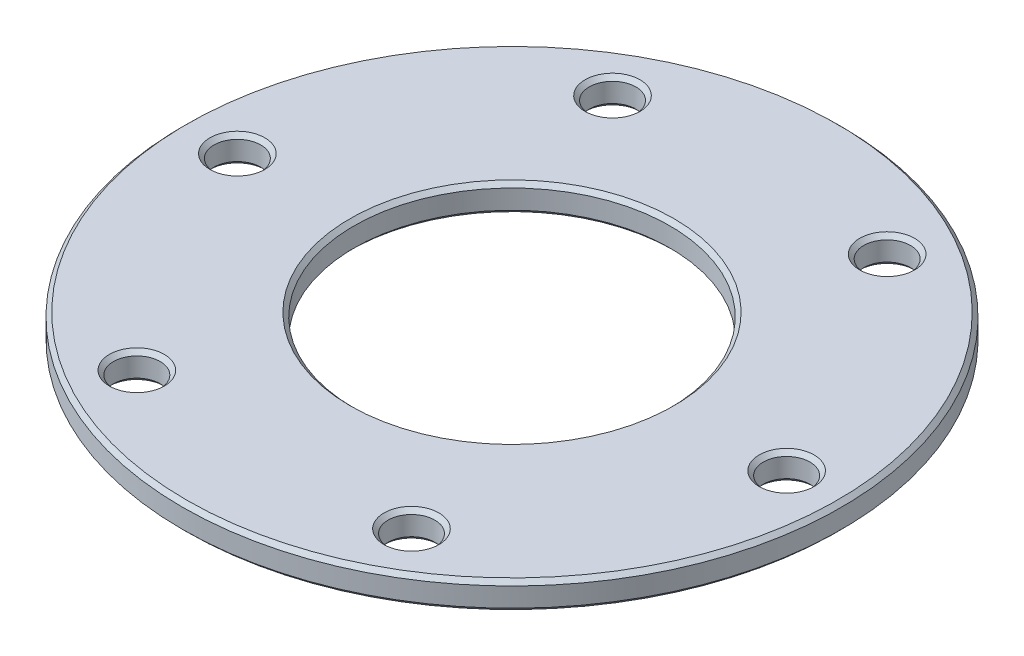
from build123d import *

# Parameters (mm, degrees)
SKETCH1_R           = 24
SKETCH1_R_2         = 11.5
BOSS_EXTRUDE1_DEPTH = 2
SKETCH2_R           = 1.7
CUT_EXTRUDE1_DEPTH  = 3
CHAMFER2_SIZE       = 0.3


with BuildPart() as part:
    # Sketch1 → Boss-Extrude1 (new body)
    with BuildSketch(Plane(origin=(0, 0, 0), x_dir=(1, 0, 0), z_dir=(0, 1, 0))):
        Circle(SKETCH1_R)
        Circle(SKETCH1_R_2, mode=Mode.SUBTRACT)
    extrude(amount=BOSS_EXTRUDE1_DEPTH)

    # Sketch2 → Cut-Extrude1 (cut, through all)
    with BuildSketch(Plane(origin=(0, 2, 0), x_dir=(1, 0, 0), z_dir=(0, 1, 0))):
        with Locations((-20, 0)):
            Circle(SKETCH2_R)
        with Locations((-10, 17.320508076)):
            Circle(SKETCH2_R)
        with Locations((10, 17.320508076)):
            Circle(SKETCH2_R)
        with Locations((20, 0)):
            Circle(SKETCH2_R)
        with Locations((10, -17.320508076)):
            Circle(SKETCH2_R)
        with Locations((-10, -17.320508076)):
            Circle(SKETCH2_R)
    extrude(amount=-CUT_EXTRUDE1_DEPTH, mode=Mode.SUBTRACT)

    # Chamfer2
    chamfer2_edges = [part.edges().sort_by_distance(p)[0] for p in [
        (-21.7, 0, 0),
        (-21.7, 2, 0),
        (-24, 0, 0),
        (-11.7, 0, 17.320508076),
        (-11.7, 2, 17.320508076),
        (8.3, 0, 17.320508076),
        (8.3, 2, 17.320508076),
        (18.3, 0, 0),
        (18.3, 2, 0),
        (8.3, 0, -17.320508076),
        (8.3, 2, -17.320508076),
        (-11.7, 0, -17.320508076),
        (-11.7, 2, -17.320508076),
        (-24, 2, 0),
        (-11.5, 0, 0),
        (-11.5, 2, 0),
    ]]
    chamfer(chamfer2_edges, length=CHAMFER2_SIZE)


solid = part.part
